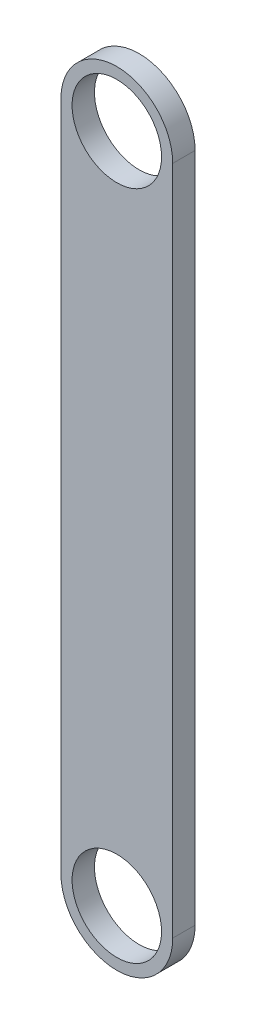
from build123d import *

# Parameters (mm, degrees)
SKETCH1_R           = 20
BOSS_EXTRUDE1_DEPTH = 10
SCALE2_SCALE        = 0.1


with BuildPart() as part:
    # Sketch1 → Boss-Extrude1 (new body)
    with BuildSketch(Plane.XY):
        with BuildLine():
            Line((-25, -150), (-25, 150))
            ThreePointArc((-25, 150), (0, 175), (25, 150))
            Line((25, 150), (25, -150))
            ThreePointArc((25, -150), (0, -175), (-25, -150))
        make_face()
        with Locations((0, 150)):
            Circle(SKETCH1_R, mode=Mode.SUBTRACT)
        with Locations((0, -150)):
            Circle(SKETCH1_R, mode=Mode.SUBTRACT)
    extrude(amount=BOSS_EXTRUDE1_DEPTH)


with BuildPart() as part_1:
    # Scale2: scaled about (0, 0, 5)
    add(part.part.scale(SCALE2_SCALE).moved(Location((0, 0, 4.5))))


solid = part_1.part
